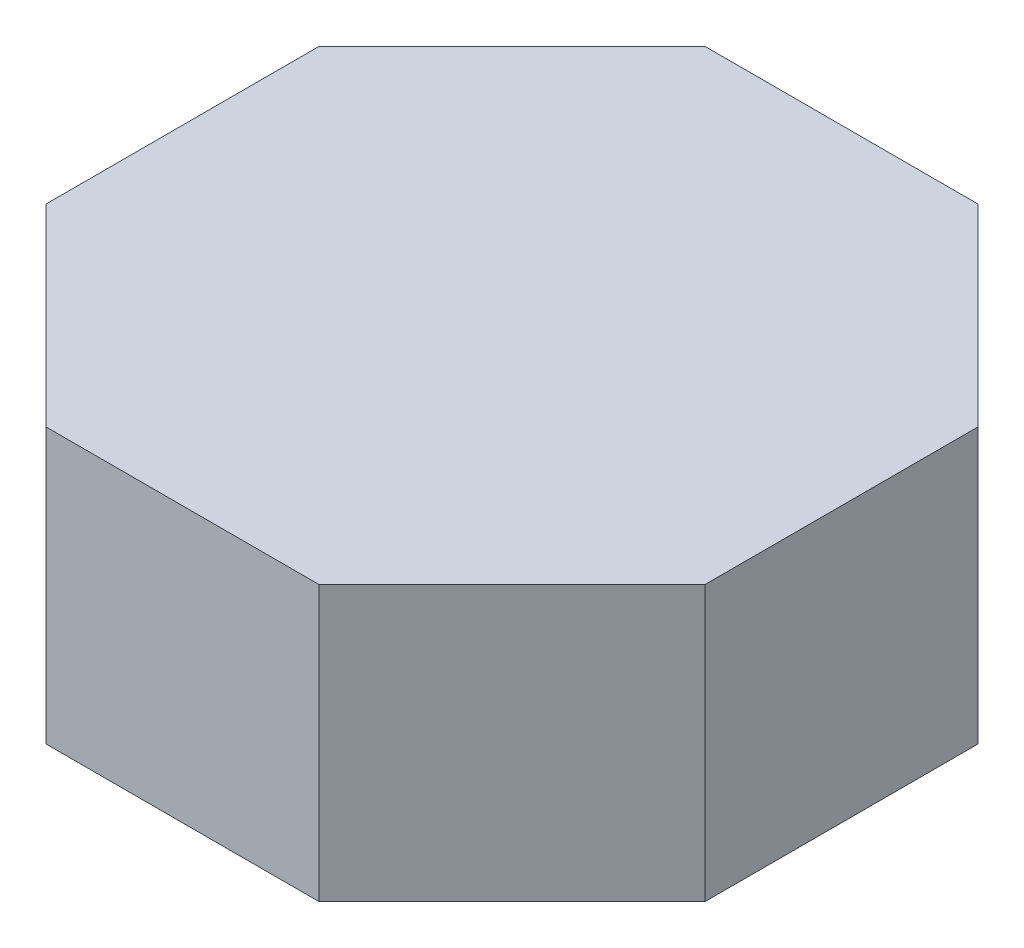
from build123d import *

# Parameters (mm, degrees)
SALIENTE_EXTRUIR1_DEPTH = 250


with BuildPart() as part:
    # Croquis1 → Saliente-Extruir1 (new body)
    with BuildSketch(Plane(origin=(0, 0, 0), x_dir=(1, 0, 0), z_dir=(0, 1, 0))):
        Polygon((300, -124.264068712), (300, 124.264068712), (124.264068712, 300), (-124.264068712, 300), (-300, 124.264068712), (-300, -124.264068712), (-124.264068712, -300), (124.264068712, -300), align=None)
    extrude(amount=SALIENTE_EXTRUIR1_DEPTH)


solid = part.part
